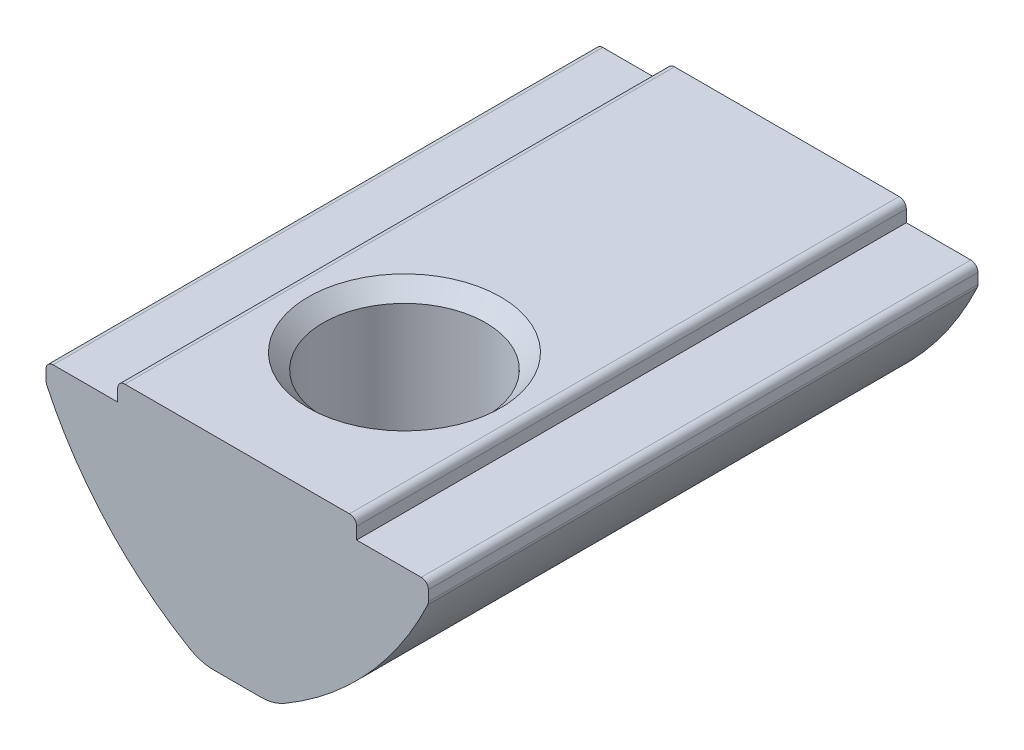
from build123d import *

# Parameters (mm, degrees)
EXTRUDE_1_DEPTH             = 11.5
FILLET_1_R                  = 0.3
FILLET_2_R                  = 2
HOLE_WIZARD_M83_D           = 6.8
HOLE_WIZARD_M83_CSINK_D     = 8.05
HOLE_WIZARD_M83_CSINK_ANGLE = 90


with BuildPart() as part:
    # Эскиз1 → Бобышка-Вытянуть1 (new body, symmetric)
    with BuildSketch(Plane.XY):
        with BuildLine():
            Line((-5, 0), (5, 0))
            Line((5, 0), (5, -0.8))
            Line((5, -0.8), (8, -0.8))
            Line((8, -0.8), (8, -1.6))
            ThreePointArc((8, -1.6), (5.309398779, -5.576969864), (1.5, -8.5))
            Line((1.5, -8.5), (-1.5, -8.5))
            ThreePointArc((-1.5, -8.5), (-5.309398779, -5.576969864), (-8, -1.6))
            Line((-8, -1.6), (-8, -0.8))
            Line((-8, -0.8), (-5, -0.8))
            Line((-5, -0.8), (-5, 0))
        make_face()
    extrude(amount=EXTRUDE_1_DEPTH, both=True)

    # Скругление1
    fillet_1_edges = [part.edges().sort_by_distance(p)[0] for p in [
        (8, -0.8, 0),
        (8, -1.6, 0),
        (-8, -1.6, 0),
        (-8, -0.8, 0),
        (-5, 0, 0),
        (5, 0, 0),
    ]]
    fillet(fillet_1_edges, radius=FILLET_1_R)

    # Скругление2
    fillet_2_edges = [part.edges().sort_by_distance(p)[0] for p in [
        (1.5, -8.5, 0),
        (-1.5, -8.5, 0),
    ]]
    fillet(fillet_2_edges, radius=FILLET_2_R)

    # Отверстие обработанное метчиком M83 (through all)
    with Locations(Plane(origin=(0, 0, 0), x_dir=(1, 0, 0), z_dir=(0, 1, 0))):
        with Locations((0, -4.5)):
            CounterSinkHole(HOLE_WIZARD_M83_D / 2, HOLE_WIZARD_M83_CSINK_D / 2, counter_sink_angle=HOLE_WIZARD_M83_CSINK_ANGLE)

    # Эскиз5 → Повернуть1 (revolve)
    with BuildSketch(Plane(origin=(0, 0, 0), x_dir=(0, 0, -1), z_dir=(1, 0, 0))):
        with BuildLine():
            Line((6.5, -4.3), (6.5, -9.3))
            ThreePointArc((6.5, -9.3), (4, -6.8), (6.5, -4.3))
        make_face()
    revolve(axis=Axis((0, -4.3, -6.5), (0, -1, 0)))


solid = part.part
